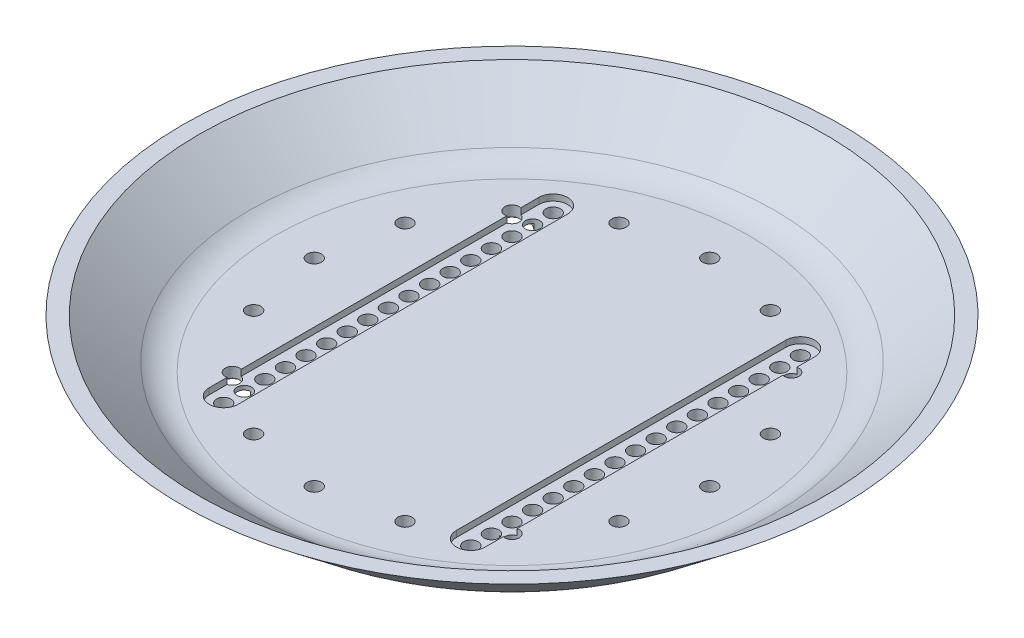
from build123d import *

# Parameters (mm, degrees)
SKETCH2_R            = 1.75
CUT_EXTRUDE1_DEPTH   = 17
LPATTERN1_COUNT      = 9
LPATTERN1_PITCH      = 5
LPATTERN1_COUNT_DIR2 = 5
LPATTERN1_PITCH_DIR2 = 10
SKETCH3_R            = 1.75
CUT_EXTRUDE2_DEPTH   = 17
SKETCH4_R            = 3.75
CUT_EXTRUDE3_DEPTH   = 1.5
CIRPATTERN1_COUNT    = 16
CUT_EXTRUDE4_DEPTH   = 1.5


with BuildPart() as part:
    # Sketch1 → Revolve1 (revolve)
    with BuildSketch(Plane.XY):
        with BuildLine():
            Line((0, 0), (-56.492189406, 0))
            ThreePointArc((-56.492189406, 0), (-59.802258821, 0.563716808), (-62.739139882, 2.191311906))
            Line((-62.739139882, 2.191311906), (-80, 16))
            Line((-80, 16), (-75.998047352, 16))
            Line((-75.998047352, 16), (-63.737187234, 6.191311906))
            ThreePointArc((-63.737187234, 6.191311906), (-60.800306172, 4.563716808), (-57.490236758, 4))
            Line((-57.490236758, 4), (0, 4))
            Line((0, 4), (0, 0))
        make_face()
    revolve(axis=Axis((0, 4, 0), (0, -1, 0)))

    # Sketch2 → Cut-Extrude1 (cut, through all)
    with BuildSketch(Plane.XZ):
        with Locations((-30, 0)):
            Circle(SKETCH2_R)
        with Locations((30, 0)):
            Circle(SKETCH2_R)
    cut_extrude1 = extrude(amount=-CUT_EXTRUDE1_DEPTH, mode=Mode.SUBTRACT)

    # LPattern1: Cut-Extrude1 9 × 5
    with Locations(*[Vector(0, 0, 1) * (i * LPATTERN1_PITCH) + Vector(0, 0, -1) * (j * LPATTERN1_PITCH_DIR2) for i in range(LPATTERN1_COUNT) for j in range(LPATTERN1_COUNT_DIR2) if (i, j) != (0, 0)]):
        add(cut_extrude1, mode=Mode.SUBTRACT)

    # Sketch3 → Cut-Extrude2 (cut, through all)
    with BuildSketch(Plane.XZ):
        with Locations((0, 48)):
            Circle(SKETCH3_R)
    cut_extrude2 = extrude(amount=-CUT_EXTRUDE2_DEPTH, mode=Mode.SUBTRACT)

    # Sketch4 → Cut-Extrude3 (cut)
    with BuildSketch(Plane.XZ):
        with Locations((0, 48)):
            Circle(SKETCH4_R)
    cut_extrude3 = extrude(amount=-CUT_EXTRUDE3_DEPTH, mode=Mode.SUBTRACT)

    # CirPattern1: Cut-Extrude2, Cut-Extrude3 ×16 about axis
    cirpattern1_axis = Axis((0, 0, 0), (0, 1, 0))
    for i in range(1, CIRPATTERN1_COUNT):
        add(cut_extrude2.rotate(cirpattern1_axis, i * 360 / CIRPATTERN1_COUNT), mode=Mode.SUBTRACT)
        add(cut_extrude3.rotate(cirpattern1_axis, i * 360 / CIRPATTERN1_COUNT), mode=Mode.SUBTRACT)

    # Sketch5 → Cut-Extrude4 (cut)
    with BuildSketch(Plane(origin=(0, 4, 0), x_dir=(1, 0, 0), z_dir=(0, 1, 0))):
        with BuildLine():
            Line((-26.5, 40), (-26.5, -40))
            ThreePointArc((-26.5, -40), (-30, -43.5), (-33.5, -40))
            Line((-33.5, -40), (-33.5, 40))
            ThreePointArc((-33.5, 40), (-30, 43.5), (-26.5, 40))
        make_face()
        with BuildLine():
            Line((33.5, 40), (33.5, -40))
            ThreePointArc((33.5, -40), (30, -43.5), (26.5, -40))
            Line((26.5, -40), (26.5, 40))
            ThreePointArc((26.5, 40), (30, 43.5), (33.5, 40))
        make_face()
    extrude(amount=-CUT_EXTRUDE4_DEPTH, mode=Mode.SUBTRACT)


solid = part.part
